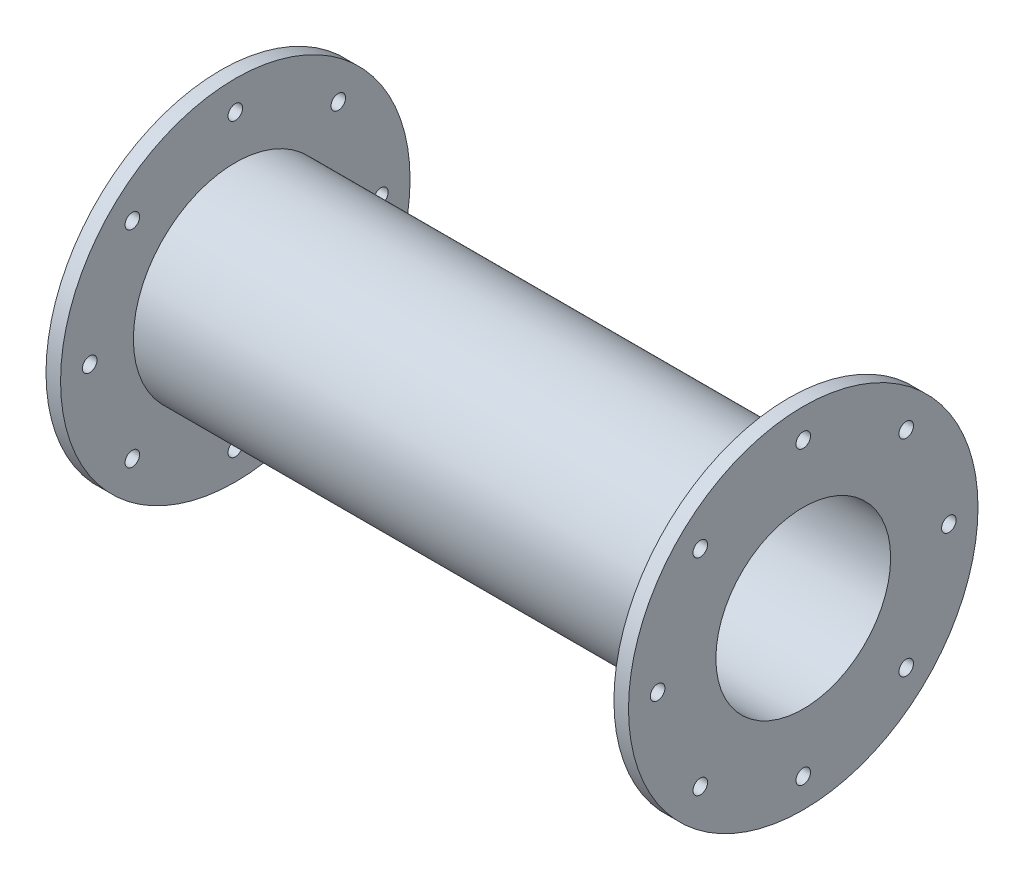
from build123d import *

# Parameters (mm, degrees)
F_1_8_0_125_DIAMETER_HOLE1_D = 3.175
CIRPATTERN1_COUNT            = 8


with BuildPart() as part:
    # Sketch1 → Revolve1 (revolve)
    with BuildSketch(Plane.XY):
        Polygon((0, 38.1), (0, 19.05), (-127, 19.05), (-127, 38.1), (-123.825, 38.1), (-123.825, 22.225), (-3.175, 22.225), (-3.175, 38.1), align=None)
    revolve(axis=Axis((-152.49, 0, 0), (1, 0, 0)))

    # 1/8 (0.125) Diameter Hole1 (through all)
    with Locations(Plane(origin=(0, 0, 0), x_dir=(0, 0, -1), z_dir=(1, 0, 0))):
        with Locations((0, 31.75)):
            f_1_8_0_125_diameter_hole1 = Hole(F_1_8_0_125_DIAMETER_HOLE1_D / 2)

    # CirPattern1: 1/8 (0.125) Diameter Hole1 ×8 about axis
    cirpattern1_axis = Axis((0, 0, 0), (1, 0, 0))
    for i in range(1, CIRPATTERN1_COUNT):
        add(f_1_8_0_125_diameter_hole1.rotate(cirpattern1_axis, i * 360 / CIRPATTERN1_COUNT), mode=Mode.SUBTRACT)


solid = part.part
